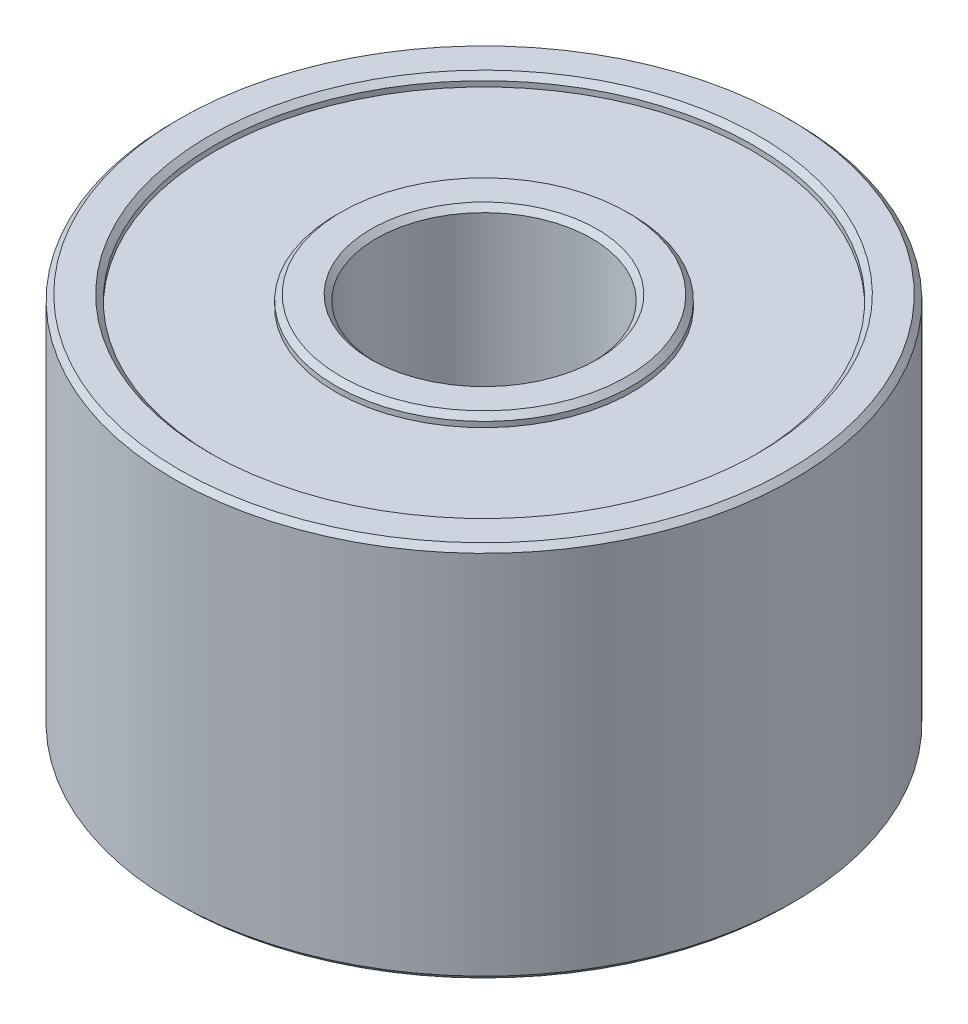
from build123d import *

# Parameters (mm, degrees)
SKETCH_1_R          = 11.5
EXTRUDE_1_DEPTH     = 14
SKETCH_2_R          = 4
CUT_EXTRUDE_1_DEPTH = 24
SKETCH_3_R          = 10
SKETCH_3_R_2        = 5.5
CUT_EXTRUDE_2_DEPTH = 0.4
SKETCH_4_R          = 10
SKETCH_4_R_2        = 5.5
CUT_EXTRUDE_3_DEPTH = 0.4
CHAMFER_1_SIZE      = 0.2


with BuildPart() as part:
    # 草图1 → 凸台-拉伸1 (new body)
    with BuildSketch(Plane(origin=(0, 0, 0), x_dir=(1, 0, 0), z_dir=(0, 1, 0))):
        Circle(SKETCH_1_R)
    extrude(amount=EXTRUDE_1_DEPTH)

    # 草图2 → 切除-拉伸1 (cut)
    with BuildSketch(Plane(origin=(0, 14, 0), x_dir=(1, 0, 0), z_dir=(0, 1, 0))):
        Circle(SKETCH_2_R)
    extrude(amount=-CUT_EXTRUDE_1_DEPTH, mode=Mode.SUBTRACT)

    # 草图3 → 切除-拉伸2 (cut)
    with BuildSketch(Plane(origin=(0, 14, 0), x_dir=(1, 0, 0), z_dir=(0, 1, 0))):
        Circle(SKETCH_3_R)
        Circle(SKETCH_3_R_2, mode=Mode.SUBTRACT)
    extrude(amount=-CUT_EXTRUDE_2_DEPTH, mode=Mode.SUBTRACT)

    # 草图4 → 切除-拉伸3 (cut)
    with BuildSketch(Plane.XZ):
        Circle(SKETCH_4_R)
        Circle(SKETCH_4_R_2, mode=Mode.SUBTRACT)
    extrude(amount=-CUT_EXTRUDE_3_DEPTH, mode=Mode.SUBTRACT)

    # 倒角1
    chamfer_1_edges = [part.edges().sort_by_distance(p)[0] for p in [
        (-10, 14, 0),
        (-5.5, 14, 0),
        (-11.5, 0, 0),
        (-10, 0, 0),
        (-5.5, 0, 0),
        (-11.5, 14, 0),
        (-4, 0, 0),
        (-4, 14, 0),
    ]]
    chamfer(chamfer_1_edges, length=CHAMFER_1_SIZE)


solid = part.part
